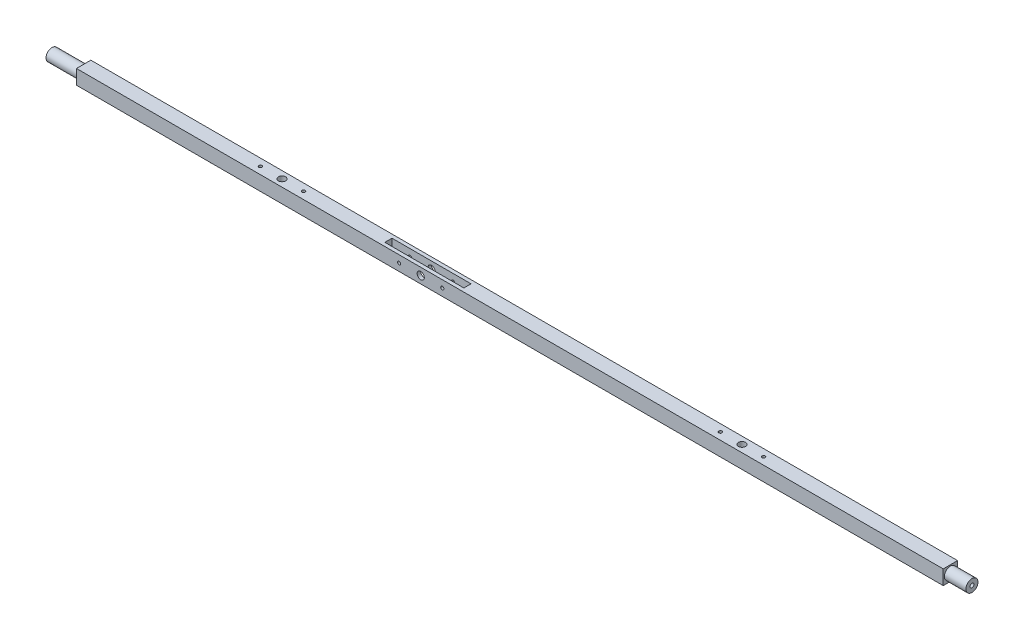
from build123d import *

# Parameters (mm, degrees)
SKETCH1_W                       = 12.7
SKETCH1_H                       = 12.82133758
LENGTH_DEPTH                    = 406.4
SKETCH2_W                       = 12.7
SKETCH2_H                       = 12.82133758
SKETCH2_R                       = 5.334
ROUND_CUT_1_DEPTH               = 19.05
SKETCH3_W                       = 12.7
SKETCH3_H                       = 12.82133758
SKETCH3_R                       = 5.334
ROUND_CUT_2_DEPTH               = 27.94
SKETCH14_R                      = 1.7526
CUT_EXTRUDE6_DEPTH              = 12.7
SKETCH15_R                      = 1.7526
CUT_EXTRUDE7_DEPTH              = 19.05
BOTTOM_WASHER_R                 = 1.4224
BOTTOM_WASHER_BOLTS_DEPTH       = 10.922
BOTTOM_WASHER_CENTER_BOLT_REACH = 14.821
SKETCH18_R                      = 3.175
TOP_WASHER_CENTER_BOLT_REACH    = 14.821
SKETCH17_R                      = 3.175
SKETCH16_R                      = 1.4224
TOP_WASHER_DEPTH                = 10.922
SKETCH19_W                      = 69.85
SKETCH19_H                      = 6.35
CUT_EXTRUDE8_DEPTH              = 13.82133758
SKETCH20_R                      = 1.397
SKETCH20_R_2                    = 3.175
CUT_EXTRUDE9_DEPTH              = 13.7


with BuildPart() as part:
    # Sketch1 → Length (new body, symmetric)
    with BuildSketch(Plane(origin=(0, 0, 0), x_dir=(0, 0, -1), z_dir=(1, 0, 0))):
        Rectangle(SKETCH1_W, SKETCH1_H)
    extrude(amount=LENGTH_DEPTH, both=True)

    # Sketch2 → Round Cut 1 (cut)
    with BuildSketch(Plane(origin=(406.4, 0, 0), x_dir=(0, 0, -1), z_dir=(1, 0, 0))):
        Rectangle(SKETCH2_W, SKETCH2_H)
        Circle(SKETCH2_R, mode=Mode.SUBTRACT)
    extrude(amount=-ROUND_CUT_1_DEPTH, mode=Mode.SUBTRACT)

    # Sketch3 → Round Cut 2 (cut)
    with BuildSketch(Plane.ZY.offset(406.4)):
        Rectangle(SKETCH3_W, SKETCH3_H)
        Circle(SKETCH3_R, mode=Mode.SUBTRACT)
    extrude(amount=-ROUND_CUT_2_DEPTH, mode=Mode.SUBTRACT)

    # Sketch14 → Cut-Extrude6 (cut)
    with BuildSketch(Plane(origin=(406.4, 0, 0), x_dir=(0, 0, -1), z_dir=(1, 0, 0))):
        Circle(SKETCH14_R)
    extrude(amount=-CUT_EXTRUDE6_DEPTH, mode=Mode.SUBTRACT)

    # Sketch15 → Cut-Extrude7 (cut)
    with BuildSketch(Plane.ZY.offset(406.4)):
        Circle(SKETCH15_R)
    extrude(amount=-CUT_EXTRUDE7_DEPTH, mode=Mode.SUBTRACT)

    # Bottom Washer → Bottom washer bolts (cut)
    with BuildSketch(Plane(origin=(0, 6.41066879, 0), x_dir=(1, 0, 0), z_dir=(0, 1, 0))):
        with Locations((-222.25, 0)):
            Circle(BOTTOM_WASHER_R)
        with Locations((-184.15, 0)):
            Circle(BOTTOM_WASHER_R)
    extrude(amount=-BOTTOM_WASHER_BOLTS_DEPTH, mode=Mode.SUBTRACT)

    # Sketch18 → Bottom Washer Center Bolt (cut, up to next)
    with BuildSketch(Plane(origin=(0, 6.41066879, 0), x_dir=(1, 0, 0), z_dir=(0, 1, 0)), mode=Mode.PRIVATE) as bottom_washer_center_bolt_sk1:
        with Locations((-203.2, 0)):
            Circle(SKETCH18_R)
    bottom_washer_center_bolt_tool1 = extrude(bottom_washer_center_bolt_sk1.sketch, amount=-BOTTOM_WASHER_CENTER_BOLT_REACH, mode=Mode.PRIVATE) & part.part
    add(bottom_washer_center_bolt_tool1.solids().sort_by_distance((-203.2, 6.410669, 0))[0], mode=Mode.SUBTRACT)

    # Sketch17 → Top Washer Center Bolt (cut, up to next)
    with BuildSketch(Plane(origin=(0, 6.41066879, 0), x_dir=(1, 0, 0), z_dir=(0, 1, 0)), mode=Mode.PRIVATE) as top_washer_center_bolt_sk1:
        with Locations((203.2, 0)):
            Circle(SKETCH17_R)
    top_washer_center_bolt_tool1 = extrude(top_washer_center_bolt_sk1.sketch, amount=-TOP_WASHER_CENTER_BOLT_REACH, mode=Mode.PRIVATE) & part.part
    add(top_washer_center_bolt_tool1.solids().sort_by_distance((203.2, 6.410669, 0))[0], mode=Mode.SUBTRACT)

    # Sketch16 → Top Washer (cut)
    with BuildSketch(Plane(origin=(0, 6.41066879, 0), x_dir=(1, 0, 0), z_dir=(0, 1, 0))):
        with Locations((222.25, 0)):
            Circle(SKETCH16_R)
        with Locations((184.15, 0)):
            Circle(SKETCH16_R)
    extrude(amount=-TOP_WASHER_DEPTH, mode=Mode.SUBTRACT)

    # Sketch19 → Cut-Extrude8 (cut, through all)
    with BuildSketch(Plane(origin=(0, -6.41066879, 0), x_dir=(-1, 0, 0), z_dir=(0, -1, 0))):
        with Locations((74.285606639, 0)):
            Rectangle(SKETCH19_W, SKETCH19_H)
    extrude(amount=-CUT_EXTRUDE8_DEPTH, mode=Mode.SUBTRACT)

    # Sketch20 → Cut-Extrude9 (cut, through all)
    with BuildSketch(Plane.XY.offset(6.35)):
        with Locations((-93.335606639, 0)):
            Circle(SKETCH20_R)
        with Locations((-74.285606639, 0)):
            Circle(SKETCH20_R_2)
        with Locations((-55.235606639, 0)):
            Circle(SKETCH20_R)
    extrude(amount=-CUT_EXTRUDE9_DEPTH, mode=Mode.SUBTRACT)


solid = part.part
